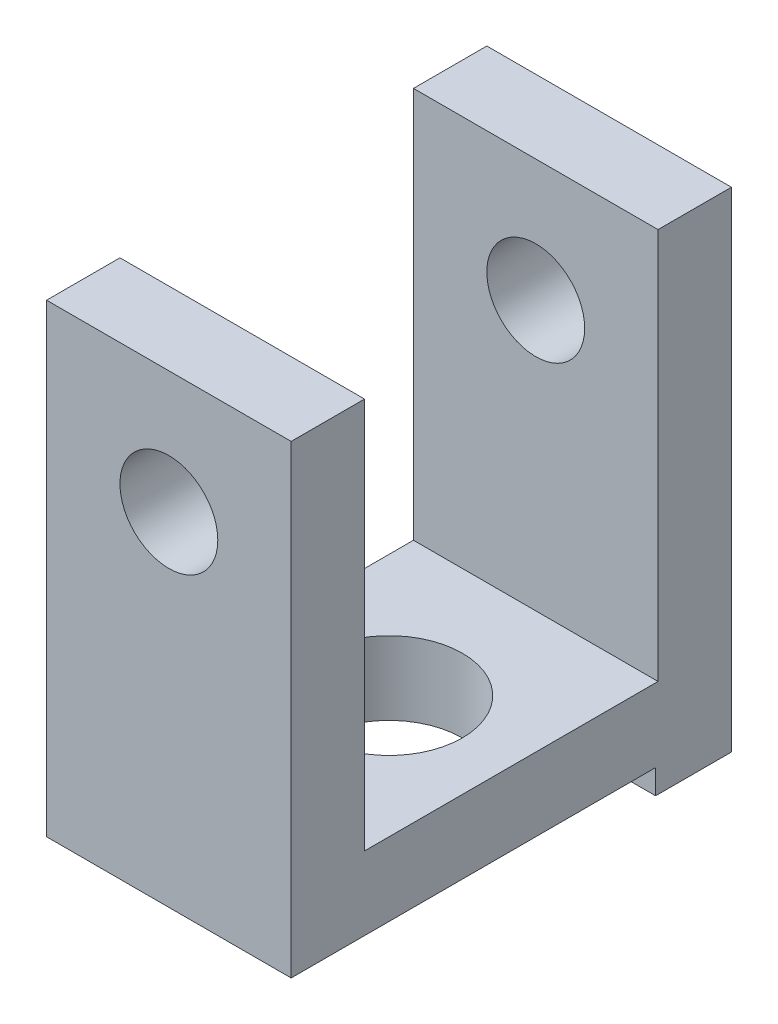
from build123d import *

# Parameters (mm, degrees)
SKETCH_1_W          = 10
SKETCH_1_H          = 18
SKETCH_1_R          = 3
EXTRUDE_2_DEPTH     = 4
SKETCH_3_W          = 10
SKETCH_3_H          = 3
EXTRUDE_3_DEPTH     = 16
SKETCH_4_R          = 2
CUT_EXTRUDE_1_DEPTH = 19
SKETCH_6_W          = 10
SKETCH_6_H          = 14.9
CUT_EXTRUDE_2_DEPTH = 1


with BuildPart() as part:
    # 草图1 → 凸台-拉伸2 (new body)
    with BuildSketch(Plane(origin=(0, 0, 0), x_dir=(1, 0, 0), z_dir=(0, 1, 0))):
        Rectangle(SKETCH_1_W, SKETCH_1_H)
        Circle(SKETCH_1_R, mode=Mode.SUBTRACT)
    extrude(amount=EXTRUDE_2_DEPTH)

    # 草图3 → 凸台-拉伸3 (add)
    with BuildSketch(Plane(origin=(0, 4, 0), x_dir=(1, 0, 0), z_dir=(0, 1, 0))):
        with Locations((0, -7.5)):
            Rectangle(SKETCH_3_W, SKETCH_3_H)
    extrude_3 = extrude(amount=EXTRUDE_3_DEPTH)

    # 草图4 → 切除-拉伸1 (cut, through all)
    with BuildSketch(Plane.XY.offset(9)):
        with Locations((0, 15)):
            Circle(SKETCH_4_R)
    cut_extrude_1 = extrude(amount=-CUT_EXTRUDE_1_DEPTH, mode=Mode.SUBTRACT)

    # 镜向1: 凸台-拉伸3, 切除-拉伸1 across plane
    add(extrude_3.mirror(Plane.XY))
    add(cut_extrude_1.mirror(Plane.XY), mode=Mode.SUBTRACT)

    # 草图6 → 切除-拉伸2 (cut)
    with BuildSketch(Plane.XZ):
        with Locations((0, 1.55)):
            Rectangle(SKETCH_6_W, SKETCH_6_H)
    extrude(amount=-CUT_EXTRUDE_2_DEPTH, mode=Mode.SUBTRACT)


solid = part.part
